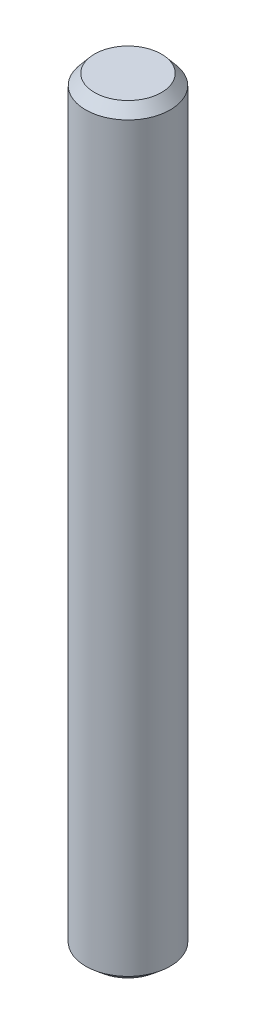
from build123d import *

# Parameters (mm, degrees)
ESQUISSE1_R             = 4
BOSS_EXTRU_1_DEPTH      = 72
CHANFREIN1_SIZE         = 1
CHANFREIN1_SIZE2        = 0.839099631
CHANFREIN1_PART_2_SIZE  = 1
CHANFREIN1_PART_2_SIZE2 = 0.839099631


with BuildPart() as part:
    # Esquisse1 → Boss.-Extru.1 (new body)
    with BuildSketch(Plane(origin=(0, 0, 0), x_dir=(1, 0, 0), z_dir=(0, 1, 0))):
        Circle(ESQUISSE1_R)
    extrude(amount=BOSS_EXTRU_1_DEPTH)

    # Chanfrein1
    chanfrein1_edges = [part.edges().sort_by_distance(p)[0] for p in [
        (-4, 0, 0),
    ]]
    chanfrein1_side = [part.faces().sort_by_distance(p)[0] for p in [
        (0, 0, 0),
    ]]
    chamfer(chanfrein1_edges, length=CHANFREIN1_SIZE, length2=CHANFREIN1_SIZE2, reference=chanfrein1_side[0])

    # Chanfrein1 part 2
    chanfrein1_part_2_edges = [part.edges().sort_by_distance(p)[0] for p in [
        (-4, 72, 0),
    ]]
    chanfrein1_part_2_side = [part.faces().sort_by_distance(p)[0] for p in [
        (-4, 36, 0),
    ]]
    chamfer(chanfrein1_part_2_edges, length=CHANFREIN1_PART_2_SIZE, length2=CHANFREIN1_PART_2_SIZE2, reference=chanfrein1_part_2_side[0])


solid = part.part
